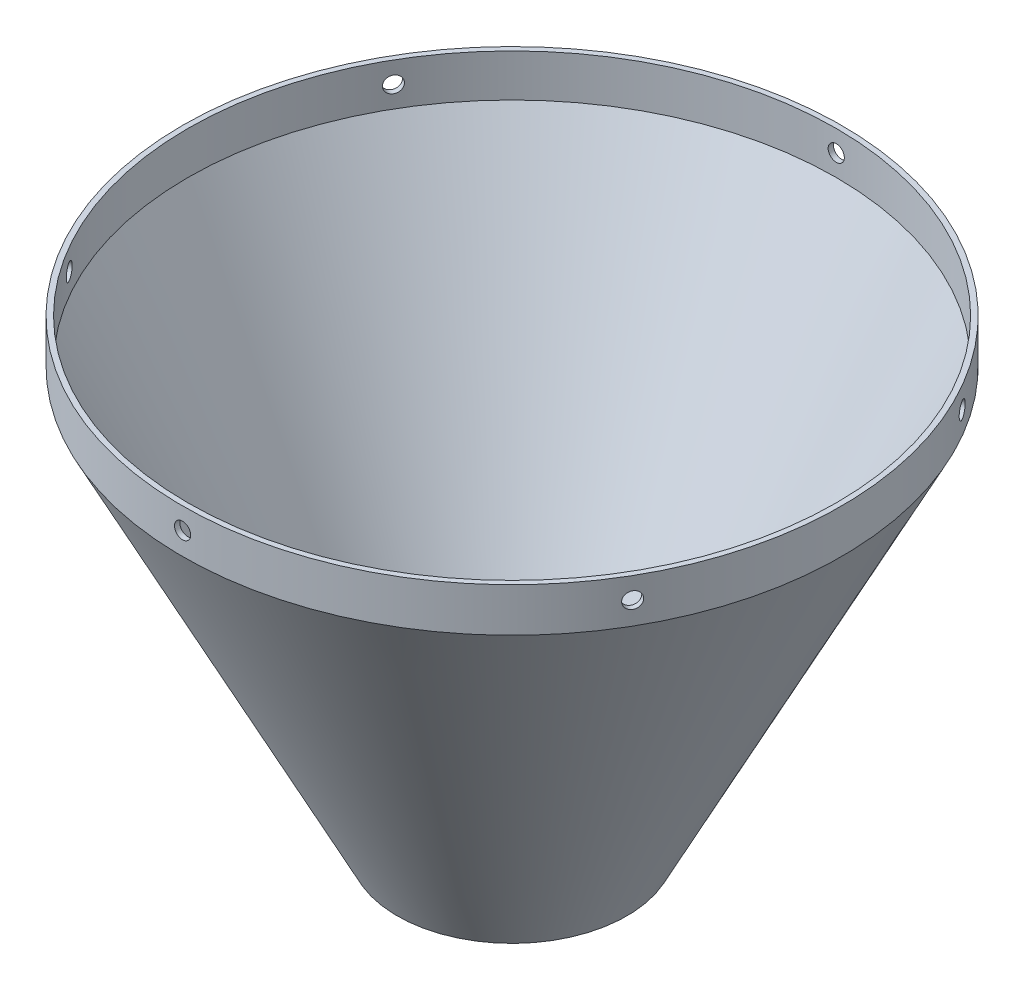
from build123d import *

# Parameters (mm, degrees)
SKETCH2_R          = 2.413
CUT_EXTRUDE1_DEPTH = 99.425
CIRPATTERN1_COUNT  = 6


with BuildPart() as part:
    # Sketch1 → Revolve1 (revolve)
    with BuildSketch(Plane.XY):
        Polygon((96.8375, 0), (96.8375, 12.7), (98.425, 12.7), (98.425, -0.383318861), (34.307471211, -125.4125), (33.3375, -125.4125), (33.3375, -123.825), align=None)
    revolve(axis=Axis((0, 0, 0), (0, -1, 0)))

    # Sketch2 → Cut-Extrude1 (cut, symmetric)
    with BuildSketch(Plane.XY):
        with Locations((0, 6.35)):
            Circle(SKETCH2_R)
    cut_extrude1 = extrude(amount=CUT_EXTRUDE1_DEPTH, both=True, mode=Mode.SUBTRACT)

    # CirPattern1: Cut-Extrude1 ×6 about axis
    cirpattern1_axis = Axis((0, 12.7, 0), (0, 1, 0))
    for i in range(1, CIRPATTERN1_COUNT):
        add(cut_extrude1.rotate(cirpattern1_axis, i * 360 / CIRPATTERN1_COUNT), mode=Mode.SUBTRACT)


solid = part.part
